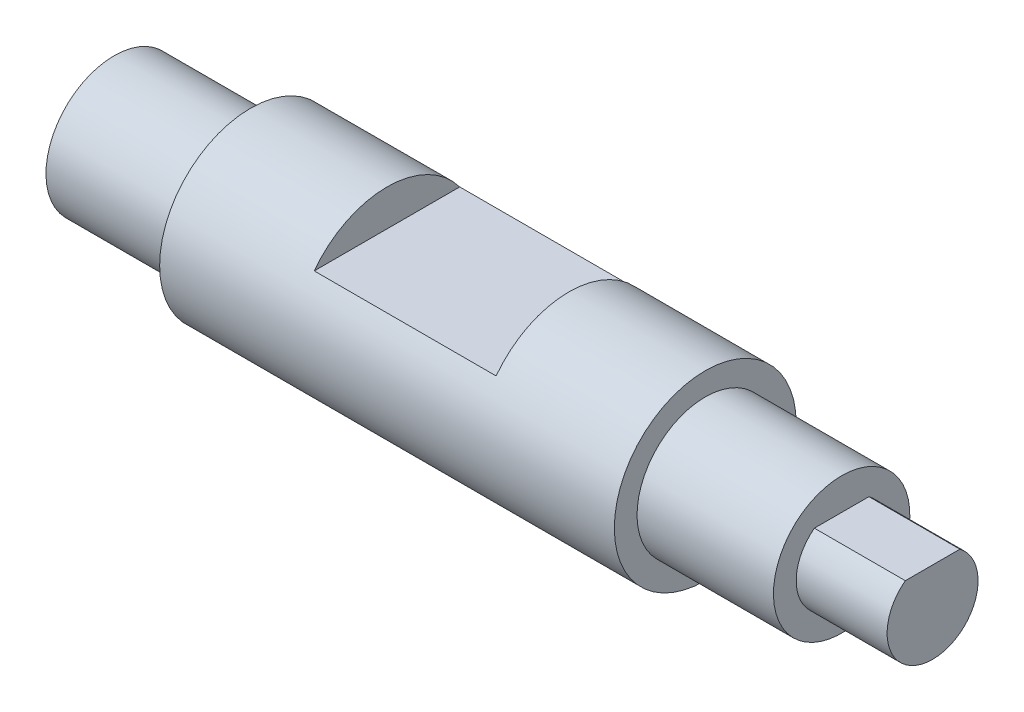
from build123d import *

# Parameters (mm, degrees)
IZIM3_W               = 20
IZIM3_H               = 8.956518763
IZIM3_W_2             = 16.233107577
IZIM3_H_2             = 7.025571552
KES_EKSTR_ZYON1_DEPTH = 30


with BuildPart() as part:
    # Çizim1 → Döndür2 (revolve)
    with BuildSketch(Plane.XY):
        Polygon((0, 0), (0, 7.5), (15, 7.5), (15, 10), (65, 10), (65, 7.5), (80, 7.5), (80, 5), (90, 5), (90, 0), align=None)
    revolve(axis=Axis((90, 0, 0), (-1, 0, 0)))

    # Çizim3 → Kes-Ekstrüzyon1 (cut, symmetric)
    with BuildSketch(Plane.XY):
        with Locations((40, 10.478259381)):
            Rectangle(IZIM3_W, IZIM3_H)
        with Locations((88.116553788, 7.512785776)):
            Rectangle(IZIM3_W_2, IZIM3_H_2)
    extrude(amount=KES_EKSTR_ZYON1_DEPTH, both=True, mode=Mode.SUBTRACT)


solid = part.part
